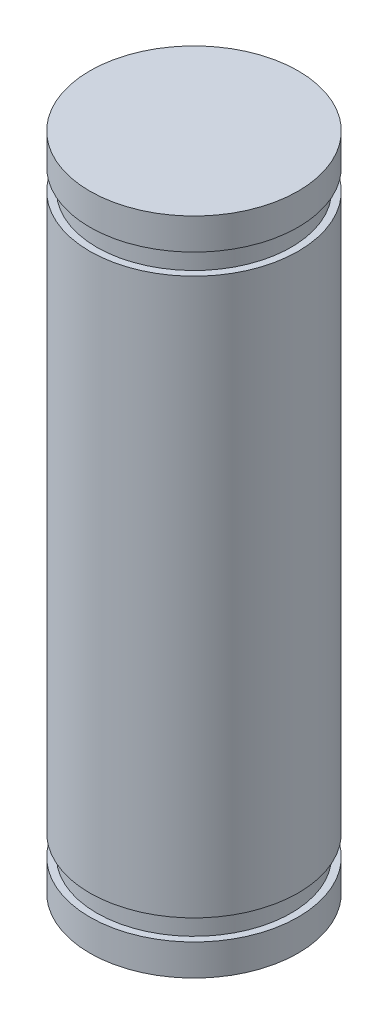
from build123d import *


with BuildPart() as part:
    # 草图1 → 旋转1 (revolve)
    with BuildSketch(Plane.XY):
        Polygon((0, -9.5), (3, -9.5), (3, -8.6), (2.8, -8.6), (2.8, -8), (3, -8), (3, 8), (2.8, 8), (2.8, 8.6), (3, 8.6), (3, 9.5), (0, 9.5), align=None)
    revolve(axis=Axis((0, 9.5, 0), (0, -1, 0)))


solid = part.part
